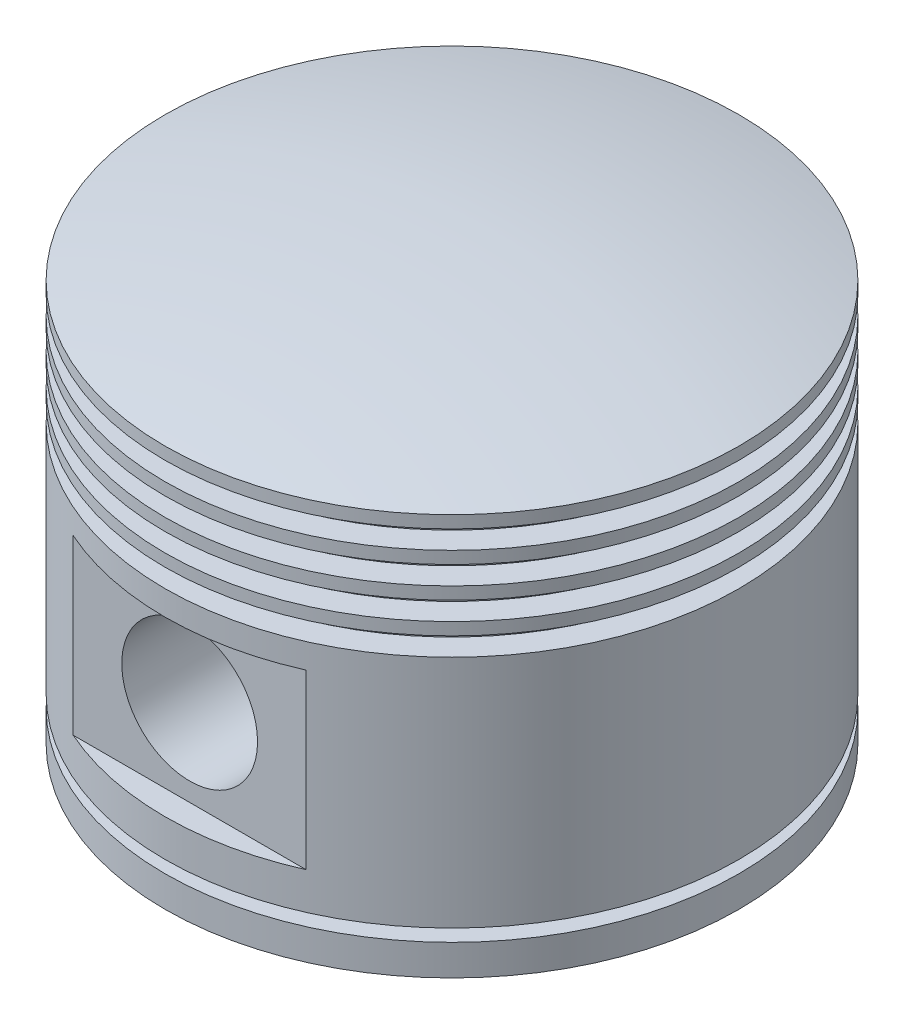
from build123d import *

# Parameters (mm, degrees)
BOSS_EXTRUDE1_REACH     = 112.854
SKETCH2_R               = 19.5
CUT_EXTRUDE1_DEPTH      = 97.636205083
CUT_EXTRUDE1_DEPTH_BACK = 97.636205083
SKETCH3_R               = 11
SKETCH4_W               = 8
SKETCH4_H               = 28
CUT_EXTRUDE2_DEPTH      = 97.636205083


with BuildPart() as part:
    # Sketch1 → Revolve1 (revolve)
    with BuildSketch(Plane.XY):
        with BuildLine():
            Line((-46.5, -5.81), (-46.5, -7.81))
            Line((-46.5, -7.81), (-42.5, -7.81))
            Line((-42.5, -7.81), (-42.5, -10.81))
            Line((-42.5, -10.81), (-46.5, -10.81))
            Line((-46.5, -10.81), (-46.5, -12.81))
            Line((-46.5, -12.81), (-42.5, -12.81))
            Line((-42.5, -12.81), (-42.5, -15.81))
            Line((-42.5, -15.81), (-46.5, -15.81))
            Line((-46.5, -15.81), (-46.5, -17.81))
            Line((-46.5, -17.81), (-42.5, -17.81))
            Line((-42.5, -17.81), (-42.5, -20.81))
            Line((-42.5, -20.81), (-46.5, -20.81))
            Line((-46.5, -20.81), (-46.5, -22.81))
            Line((-46.5, -22.81), (-42.5, -22.81))
            Line((-42.5, -22.81), (-42.5, -25.81))
            Line((-42.5, -25.81), (-46.5, -25.81))
            Line((-46.5, -25.81), (-46.5, -63.81))
            Line((-46.5, -63.81), (-42.5, -63.81))
            Line((-42.5, -63.81), (-42.5, -65.81))
            Line((-42.5, -65.81), (-46.5, -65.81))
            Line((-46.5, -65.81), (-46.5, -70.81))
            Line((-46.5, -70.81), (-37, -70.81))
            Line((-37, -70.81), (-37, -8.81))
            Line((-37, -8.81), (0, -8.81))
            Line((0, -8.81), (0, 0))
            ThreePointArc((0, 0), (-23.430767144, -1.458240584), (-46.5, -5.81))
        make_face()
    revolve(axis=Axis((0, 75.597559419, 0), (0, -1, 0)))

    # Sketch2 → Boss-Extrude1 (add, up to next)
    with BuildSketch(Plane.XY.offset(25), mode=Mode.PRIVATE) as boss_extrude1_sk1:
        with Locations((0, -43.81)):
            Circle(SKETCH2_R)
    boss_extrude1_tool1 = extrude(boss_extrude1_sk1.sketch, amount=BOSS_EXTRUDE1_REACH, mode=Mode.PRIVATE) - part.part
    boss_extrude1 = boss_extrude1_tool1.solids().sort_by_distance((0, -43.81, 25))[0]
    add(boss_extrude1)

    # Mirror1: Boss-Extrude1 across plane
    add(boss_extrude1.mirror(Plane.XY))

    # Sketch3 → Cut-Extrude1 (cut, two sides: drawn at the far end of the back side and taken through both)
    with BuildSketch(Plane.XY.offset(-CUT_EXTRUDE1_DEPTH_BACK)):
        with Locations((0, -43.81)):
            Circle(SKETCH3_R)
    extrude(amount=CUT_EXTRUDE1_DEPTH + CUT_EXTRUDE1_DEPTH_BACK, mode=Mode.SUBTRACT)

    # Sketch4 → Cut-Extrude2 (cut, symmetric)
    with BuildSketch(Plane(origin=(0, 0, 0), x_dir=(0, 0, -1), z_dir=(1, 0, 0))):
        with Locations((46.5, -43.81)):
            Rectangle(SKETCH4_W, SKETCH4_H)
    cut_extrude2 = extrude(amount=CUT_EXTRUDE2_DEPTH, both=True, mode=Mode.SUBTRACT)

    # Mirror2: Cut-Extrude2 across plane
    add(cut_extrude2.mirror(Plane.XY), mode=Mode.SUBTRACT)


solid = part.part
